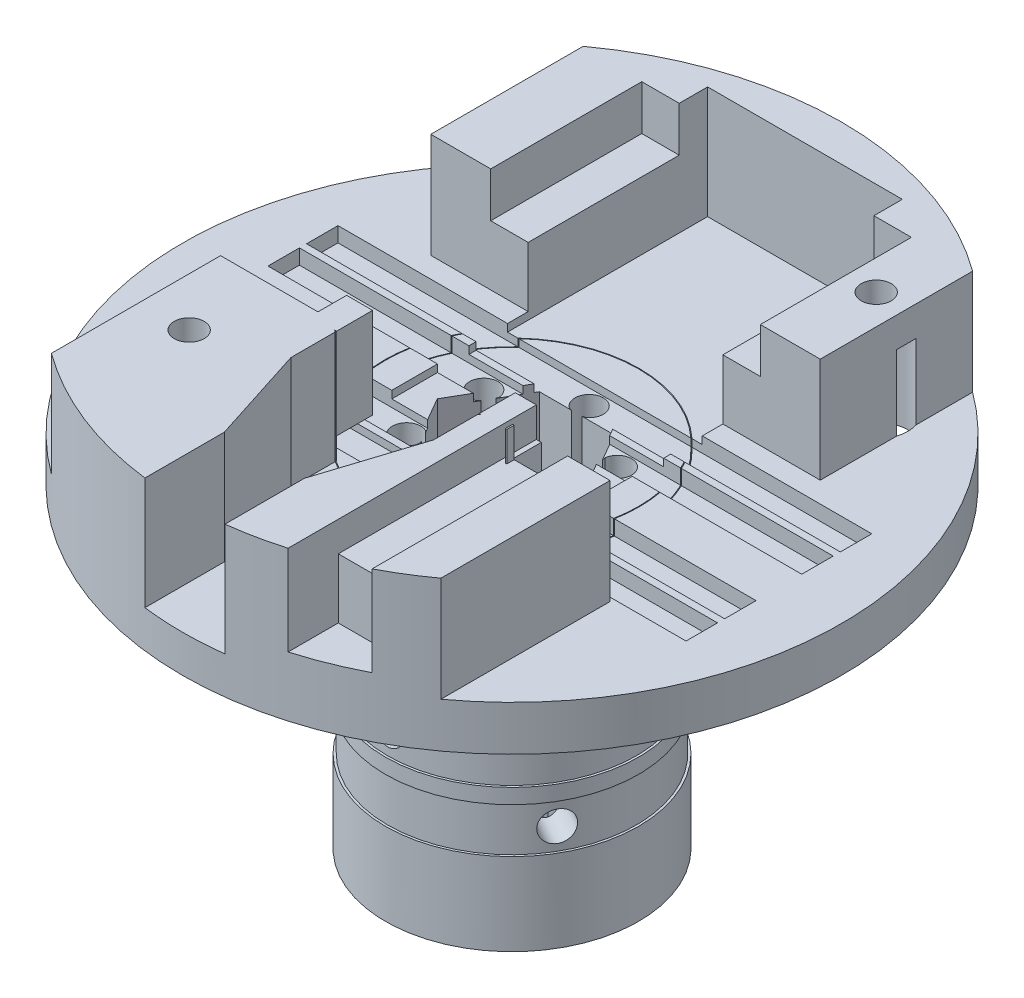
from build123d import *

# Parameters (mm, degrees)
BOSS_EXTRUDE1_DEPTH      = 8
BOSS_EXTRUDE1_DEPTH_BACK = 2
SKETCH1_R                = 22
SKETCH6_R                = 21
SKETCH6_R_2              = 12.5
CUT_EXTRUDE5_DEPTH       = 1
SKETCH7_R                = 8.5
BOSS_EXTRUDE2_DEPTH      = 21
CUT_EXTRUDE6_DEPTH       = 38.536648758
CUT_EXTRUDE6_DEPTH_BACK  = 38.536648758
SKETCH8_R                = 1.5
CUT_EXTRUDE7_DEPTH       = 7
CUT_EXTRUDE14_DEPTH      = 62
SKETCH29_W               = 18
SKETCH29_H               = 24.118038922
CUT_EXTRUDE19_DEPTH      = 3
SKETCH30_W               = 2.5
SKETCH30_H               = 14
CUT_EXTRUDE20_DEPTH      = 6
CUT_EXTRUDE28_DEPTH      = 1.5
CUT_EXTRUDE28_DEPTH_BACK = 1.5
SKETCH36_R               = 8.5
SKETCH36_R_2             = 8.3
CUT_EXTRUDE30_DEPTH      = 1.5
CUT_EXTRUDE30_DEPTH_BACK = 1.5
SKETCH39_R               = 8.5
SKETCH39_R_2             = 8.3
CUT_EXTRUDE35_DEPTH      = 39.691084244
CUT_EXTRUDE35_DEPTH_BACK = 39.691084244
SKETCH44_R               = 1
CUT_EXTRUDE36_DEPTH      = 39.691084304
CUT_EXTRUDE36_DEPTH_BACK = 39.691084304
SKETCH45_R               = 1
SKETCH47_W               = 27.732128476
SKETCH47_H               = 14.033639909
CUT_EXTRUDE38_DEPTH      = 7
CUT_EXTRUDE39_DEPTH      = 7.5
SKETCH48_R               = 1
CUT_EXTRUDE40_DEPTH      = 9
SKETCH50_R               = 6.388253867
BOSS_EXTRUDE5_DEPTH      = 2
SKETCH49_R               = 2.1
CUT_EXTRUDE42_DEPTH      = 7
SKETCH51_W               = 35.63730279
SKETCH51_H               = 2.1
CUT_EXTRUDE43_DEPTH      = 1
CUT_EXTRUDE44_DEPTH      = 2
CUT_EXTRUDE45_START      = -33.5
SKETCH53_R               = 8.5
SKETCH53_R_2             = 8.45
CUT_EXTRUDE45_DEPTH      = 33.5
CUT_EXTRUDE46_DEPTH      = 6
SKETCH55_W               = 1.737607108
SKETCH55_H               = 6.054348591
BOSS_EXTRUDE6_DEPTH      = 2.4


with BuildPart() as part:
    # Sketch1 → Boss-Extrude1 (new, two sides: drawn at the far end of the back side and taken through both)
    with BuildSketch(Plane(origin=(0, 0, 0), x_dir=(1, 0, 0), z_dir=(0, 1, 0)).offset(-BOSS_EXTRUDE1_DEPTH_BACK)):
        Circle(SKETCH1_R)
    extrude(amount=BOSS_EXTRUDE1_DEPTH + BOSS_EXTRUDE1_DEPTH_BACK)

    # Sketch6 → Cut-Extrude5 (cut)
    with BuildSketch(Plane(origin=(0, -2, 0), x_dir=(-1, 0, 0), z_dir=(0, -1, 0))):
        Circle(SKETCH6_R)
        Circle(SKETCH6_R_2, mode=Mode.SUBTRACT)
    extrude(amount=-CUT_EXTRUDE5_DEPTH, mode=Mode.SUBTRACT)

    # Sketch7 → Boss-Extrude2 (add)
    with BuildSketch(Plane(origin=(0, -2, 0), x_dir=(-1, 0, 0), z_dir=(0, -1, 0))):
        Circle(SKETCH7_R)
    extrude(amount=BOSS_EXTRUDE2_DEPTH)

    # Sketch8 → Cut-Extrude6 (cut, two sides: drawn at the far end of the back side and taken through both)
    with BuildSketch(Plane(origin=(0, -2, 0), x_dir=(-1, 0, 0), z_dir=(0, -1, 0)).offset(-CUT_EXTRUDE6_DEPTH_BACK)):
        Circle(SKETCH8_R)
    extrude(amount=CUT_EXTRUDE6_DEPTH + CUT_EXTRUDE6_DEPTH_BACK, mode=Mode.SUBTRACT)

    # Sketch9 → Cut-Extrude7 (cut)
    with BuildSketch(Plane(origin=(0, 8, 0), x_dir=(1, 0, 0), z_dir=(0, 1, 0))):
        with BuildLine():
            Line((-13.000713231, -20.359249211), (-13.000713231, 20.359249211))
            ThreePointArc((-13.000713231, 20.359249211), (-24.156108398, 0), (-13.000713231, -20.359249211))
        make_face()
        with BuildLine():
            Line((13, -20.359704638), (13, 20.359704638))
            ThreePointArc((13, 20.359704638), (24.156108398, 0), (13, -20.359704638))
        make_face()
    extrude(amount=-CUT_EXTRUDE7_DEPTH, mode=Mode.SUBTRACT)

    # Sketch17 → Cut-Extrude14 (cut)
    with BuildSketch(Plane(origin=(0, -23, 0), x_dir=(-1, 0, 0), z_dir=(0, -1, 0))):
        with BuildLine():
            Line((3.510112493, 2.562543944), (2.49433043, 4.321460529))
            Line((2.49433043, 4.321460529), (0.464363513, 4.321225889))
            Line((0.464363513, 4.321225889), (0.364363514, 4.32121433))
            Line((0.364363514, 4.32121433), (0.572663129, 4.392004656))
            ThreePointArc((0.572663129, 4.392004656), (-0.000109809, 6.099999994), (-0.572487883, 4.39187229))
            Line((-0.572487883, 4.39187229), (-0.364171908, 4.321130119))
            Line((-0.364171908, 4.321130119), (-0.464171907, 4.321118561))
            Line((-0.464171907, 4.321118561), (-2.495329385, 4.320883782))
            Line((-2.495329385, 4.320883782), (-3.510109638, 2.562763543))
            Line((-3.510109638, 2.562763543), (-3.560099628, 2.476155224))
            Line((-3.560099628, 2.476155224), (-3.517256042, 2.691943146))
            ThreePointArc((-3.517256042, 2.691943146), (-5.282809862, 3.049904899), (-4.089716915, 1.700147095))
            Line((-4.089716915, 1.700147095), (-3.924294411, 1.845182936))
            Line((-3.924294411, 1.845182936), (-3.9742844, 1.758574617))
            Line((-3.9742844, 1.758574617), (-4.989659815, -0.000576747))
            Line((-4.989659815, -0.000576747), (-3.974473152, -1.758462345))
            Line((-3.974473152, -1.758462345), (-3.924463142, -1.845059106))
            Line((-3.924463142, -1.845059106), (-4.08991917, -1.700061511))
            ThreePointArc((-4.08991917, -1.700061511), (-5.282700053, -3.050095094), (-3.517229032, -2.691725195))
            Line((-3.517229032, -2.691725195), (-3.560122503, -2.475947183))
            Line((-3.560122503, -2.475947183), (-3.510112493, -2.562543944))
            Line((-3.510112493, -2.562543944), (-2.49433043, -4.321460529))
            Line((-2.49433043, -4.321460529), (-0.464363513, -4.321225889))
            Line((-0.464363513, -4.321225889), (-0.364363514, -4.32121433))
            Line((-0.364363514, -4.32121433), (-0.572663129, -4.392004656))
            ThreePointArc((-0.572663129, -4.392004656), (0.000109809, -6.099999994), (0.572487883, -4.39187229))
            Line((0.572487883, -4.39187229), (0.364171908, -4.321130119))
            Line((0.364171908, -4.321130119), (0.464171907, -4.321118561))
            Line((0.464171907, -4.321118561), (2.495329385, -4.320883782))
            Line((2.495329385, -4.320883782), (3.510109638, -2.562763543))
            Line((3.510109638, -2.562763543), (3.560099628, -2.476155224))
            Line((3.560099628, -2.476155224), (3.517256042, -2.691943146))
            ThreePointArc((3.517256042, -2.691943146), (5.282809862, -3.049904899), (4.089716915, -1.700147095))
            Line((4.089716915, -1.700147095), (3.924294411, -1.845182936))
            Line((3.924294411, -1.845182936), (3.9742844, -1.758574617))
            Line((3.9742844, -1.758574617), (4.989659815, 0.000576747))
            Line((4.989659815, 0.000576747), (3.974473152, 1.758462345))
            Line((3.974473152, 1.758462345), (3.924463142, 1.845059106))
            Line((3.924463142, 1.845059106), (4.08991917, 1.700061511))
            ThreePointArc((4.08991917, 1.700061511), (5.282700053, 3.050095094), (3.517229032, 2.691725195))
            Line((3.517229032, 2.691725195), (3.560122503, 2.475947183))
            Line((3.560122503, 2.475947183), (3.510112493, 2.562543944))
        make_face()
    extrude(amount=-CUT_EXTRUDE14_DEPTH, mode=Mode.SUBTRACT)

    # Sketch29 → Cut-Extrude19 (cut)
    with BuildSketch(Plane(origin=(0, 8, 0), x_dir=(1, 0, 0), z_dir=(0, 1, 0))):
        with Locations((0, 5.603215798)):
            Rectangle(SKETCH29_W, SKETCH29_H)
    extrude(amount=-CUT_EXTRUDE19_DEPTH, mode=Mode.SUBTRACT)

    # Sketch30 → Cut-Extrude20 (cut)
    with BuildSketch(Plane(origin=(0, 8, 0), x_dir=(1, 0, 0), z_dir=(0, 1, 0))):
        with Locations((6.752146467, 0.544196337)):
            Rectangle(SKETCH30_W, SKETCH30_H)
        with Locations((-6.752146467, 0.544196337)):
            Rectangle(SKETCH30_W, SKETCH30_H)
    extrude(amount=-CUT_EXTRUDE20_DEPTH, mode=Mode.SUBTRACT)

    # Sketch36 → Cut-Extrude28 (cut, two sides: drawn at the far end of the back side and taken through both)
    with BuildSketch(Plane(origin=(0, -12, 0), x_dir=(1, 0, 0), z_dir=(0, 1, 0)).offset(-CUT_EXTRUDE28_DEPTH_BACK)):
        Circle(SKETCH36_R)
        Circle(SKETCH36_R_2, mode=Mode.SUBTRACT)
    extrude(amount=CUT_EXTRUDE28_DEPTH + CUT_EXTRUDE28_DEPTH_BACK, mode=Mode.SUBTRACT)

    # Sketch39 → Cut-Extrude30 (cut, two sides: drawn at the far end of the back side and taken through both)
    with BuildSketch(Plane(origin=(0, -16, 0), x_dir=(1, 0, 0), z_dir=(0, 1, 0)).offset(-CUT_EXTRUDE30_DEPTH_BACK)):
        Circle(SKETCH39_R)
        Circle(SKETCH39_R_2, mode=Mode.SUBTRACT)
    extrude(amount=CUT_EXTRUDE30_DEPTH + CUT_EXTRUDE30_DEPTH_BACK, mode=Mode.SUBTRACT)

    # Sketch44 → Cut-Extrude35 (cut, two sides: drawn at the far end of the back side and taken through both)
    with BuildSketch(Plane.XY.offset(-CUT_EXTRUDE35_DEPTH_BACK)):
        with Locations((0, -11.972418726)):
            Circle(SKETCH44_R)
    extrude(amount=CUT_EXTRUDE35_DEPTH + CUT_EXTRUDE35_DEPTH_BACK, mode=Mode.SUBTRACT)

    # Sketch45 → Cut-Extrude36 (cut, two sides: drawn at the far end of the back side and taken through both)
    with BuildSketch(Plane(origin=(0, 0, 0), x_dir=(0, 1, 0), z_dir=(0.8660254037844398, 0, 0.499999999999998)).offset(-CUT_EXTRUDE36_DEPTH_BACK)):
        with Locations((-16.047134989, 0)):
            Circle(SKETCH45_R)
    extrude(amount=CUT_EXTRUDE36_DEPTH + CUT_EXTRUDE36_DEPTH_BACK, mode=Mode.SUBTRACT)

    # Sketch47 → Cut-Extrude38 (cut)
    with BuildSketch(Plane(origin=(0, 8, 0), x_dir=(1, 0, 0), z_dir=(0, 1, 0))):
        with Locations((-0.011675811, 0.561016292)):
            Rectangle(SKETCH47_W, SKETCH47_H)
    extrude(amount=-CUT_EXTRUDE38_DEPTH, mode=Mode.SUBTRACT)

    # Sketch23 → Cut-Extrude39 (cut)
    with BuildSketch(Plane(origin=(0, 8, 0), x_dir=(1, 0, 0), z_dir=(0, 1, 0))):
        with BuildLine():
            Line((-2.670420152, -16.85816067), (-2.670420152, -16.530371213))
            Line((-2.670420152, -16.530371213), (-4.762392892, -10))
            Line((-4.762392892, -10), (-4.762392892, -6.943148259))
            Line((-4.762392892, -6.943148259), (-6.5, -6.943148259))
            Line((-6.5, -6.943148259), (-6.5, 19.556851741))
            Line((-6.5, 19.556851741), (6.5, 19.556851741))
            Line((6.5, 19.556851741), (6.5, -6.943148259))
            Line((6.5, -6.943148259), (4.762392892, -6.943148259))
            Line((4.762392892, -6.943148259), (4.762392892, -10))
            Line((4.762392892, -10), (2.670420152, -16.530371213))
            Line((2.670420152, -16.530371213), (2.670420152, -16.85816067))
            Line((2.670420152, -16.85816067), (2.670420152, -21.837327131))
            ThreePointArc((2.670420152, -21.837327131), (1.836835043, -21.92318492), (1.000584871, -21.977234355))
            Line((1.000584871, -21.977234355), (0, -25.25))
            Line((0, -25.25), (-1.000584871, -21.977234355))
            ThreePointArc((-1.000584871, -21.977234355), (-1.836835043, -21.92318492), (-2.670420152, -21.837327131))
            Line((-2.670420152, -21.837327131), (-2.670420152, -16.85816067))
        make_face()
    extrude(amount=-CUT_EXTRUDE39_DEPTH, mode=Mode.SUBTRACT)

    # Sketch48 → Cut-Extrude40 (cut)
    with BuildSketch(Plane(origin=(0, 8, 0), x_dir=(1, 0, 0), z_dir=(0, 1, 0))):
        with Locations((11, 13.315197565)):
            Circle(SKETCH48_R)
        with Locations((-9.750356615, -11.802538605)):
            Circle(SKETCH48_R)
    extrude(amount=-CUT_EXTRUDE40_DEPTH, mode=Mode.SUBTRACT)

    # Sketch50 → Boss-Extrude5 (add)
    with BuildSketch(Plane.XZ.offset(23)):
        Circle(SKETCH50_R)
        Polygon((-4.989659815, -0.000576747), (-2.49433043, -4.321460529), (2.495329385, -4.320883782), (4.989659815, 0.000576747), (2.49433043, 4.321460529), (-2.495329385, 4.320883782), align=None, mode=Mode.SUBTRACT)
    extrude(amount=-BOSS_EXTRUDE5_DEPTH)

    # Sketch49 → Cut-Extrude42 (cut)
    with BuildSketch(Plane.XZ.offset(1)):
        with Locations((-9.750356615, 11.802538605)):
            Circle(SKETCH49_R)
        with Locations((11, -13.315197565)):
            Circle(SKETCH49_R)
    extrude(amount=-CUT_EXTRUDE42_DEPTH, mode=Mode.SUBTRACT)

    # Sketch51 → Cut-Extrude43 (cut)
    with BuildSketch(Plane(origin=(0, 1, 0), x_dir=(1, 0, 0), z_dir=(0, 1, 0))):
        with Locations((0, 5.15)):
            Rectangle(SKETCH51_W, SKETCH51_H)
        with Locations((0, 2.575)):
            Rectangle(SKETCH51_W, SKETCH51_H)
        with Locations((0, -2.575)):
            Rectangle(SKETCH51_W, SKETCH51_H)
        with Locations((0, -5.15)):
            Rectangle(SKETCH51_W, SKETCH51_H)
    extrude(amount=-CUT_EXTRUDE43_DEPTH, mode=Mode.SUBTRACT)

    # Sketch52 → Cut-Extrude44 (cut)
    with BuildSketch(Plane(origin=(0, 8, 0), x_dir=(1, 0, 0), z_dir=(0, 1, 0))):
        Polygon((6.167287474, -17.764425584), (10.167287474, -17.764425584), (10.167287474, -6.455803663), (6.6, -6.455803663), (6.6, -6.943148259), (6.167287474, -6.943148259), align=None)
    extrude(amount=-CUT_EXTRUDE44_DEPTH, mode=Mode.SUBTRACT)

    # Sketch53 → Cut-Extrude45 (cut)
    with BuildSketch(Plane.XZ.offset(23).offset(CUT_EXTRUDE45_START)):
        Circle(SKETCH53_R)
        Circle(SKETCH53_R_2, mode=Mode.SUBTRACT)
    extrude(amount=CUT_EXTRUDE45_DEPTH, mode=Mode.SUBTRACT)


with BuildPart() as cut_extrude45_piece_1:
    # of the separate pieces the step leaves, piece 1, a body of its own (cut_extrude45_pieces)
    add(part.part.solids().sort_by_distance((22, 0, 0))[0])

    # Sketch54 → Cut-Extrude46 (cut)
    with BuildSketch(Plane(origin=(0, 8, 0), x_dir=(1, 0, 0), z_dir=(0, 1, 0))):
        with BuildLine():
            Line((10.167287474, -19.509645446), (10.167287474, -17.764425584))
            Line((10.167287474, -17.764425584), (6.167287474, -17.764425584))
            Line((6.167287474, -17.764425584), (6.167287474, -21.117873122))
            ThreePointArc((6.167287474, -21.117873122), (8.206776697, -20.411977274), (10.167287474, -19.509645446))
        make_face()
    extrude(amount=-CUT_EXTRUDE46_DEPTH, mode=Mode.SUBTRACT)

    # Sketch55 → Boss-Extrude6 (add)
    with BuildSketch(Plane(origin=(0, 0, 6.943148259), x_dir=(-1, 0, 0), z_dir=(0, 0, -1))):
        Polygon((-4.762392892, 8), (-6.167287474, 8), (-6.167287474, 6), (-6.5, 6), (-6.5, 1.945651409), (-4.762392892, 1.945651409), align=None)
        with Locations((5.631196446, 4.972825704)):
            Rectangle(SKETCH55_W, SKETCH55_H)
    extrude(amount=BOSS_EXTRUDE6_DEPTH)


with BuildPart() as cut_extrude45_piece_2:
    # of the separate pieces the step leaves, piece 2, a body of its own (cut_extrude45_pieces)
    add(part.part.solids().sort_by_distance((-4.816138729, 8, 6.943148259))[0])


solid = Compound([cut_extrude45_piece_1.part, cut_extrude45_piece_2.part])
